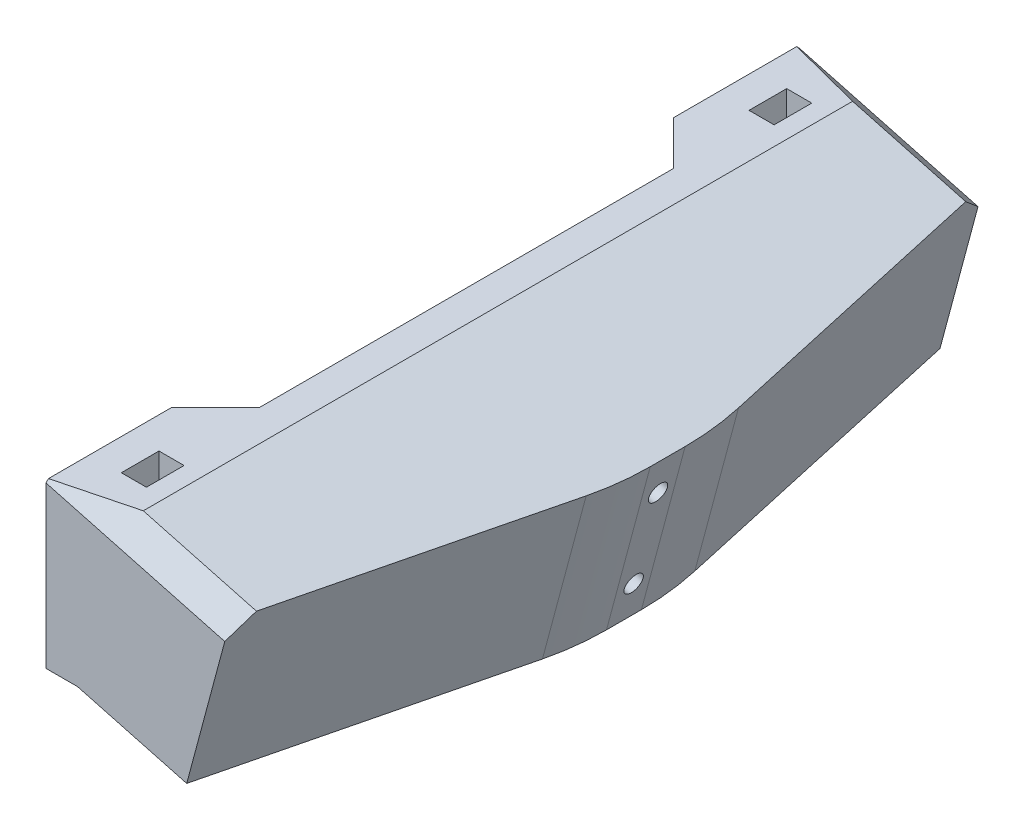
from build123d import *

# Parameters (mm, degrees)
BOSS_EXTRUDE1_DEPTH = 120
BOSS_EXTRUDE2_DEPTH = 26.917181
CUT_EXTRUDE3_DEPTH  = 34.246933562
SKETCH7_R           = 1.55
CUT_EXTRUDE4_DEPTH  = 10
CUT_EXTRUDE5_DEPTH  = 4
FILLET1_R           = 50
SKETCH10_R          = 1.5
CUT_EXTRUDE6_DEPTH  = 40.591109915
CHAMFER4_SIZE       = 3.5
SKETCH12_R          = 4
CUT_EXTRUDE8_DEPTH  = 5
SKETCH12_3_R        = 4
CUT_EXTRUDE9_DEPTH  = 9


with BuildPart() as part:
    # Sketch1 → Boss-Extrude1 (new body)
    with BuildSketch(Plane.XY):
        Polygon((12, 26), (5.033320997, 0), (22.41998587, -4.658742812), (29.386664873, 21.341257188), align=None)
        Polygon((0, 0), (0, 26), (12, 26), (5.033320997, 0), align=None)
    extrude(amount=-BOSS_EXTRUDE1_DEPTH)

    # Sketch3 → Boss-Extrude2 (add)
    with BuildSketch(Plane(origin=(7.303847577, 27.258330249, 0), x_dir=(0.965925826, -0.258819045, 0), z_dir=(0.258819045, 0.965925826, 0))):
        Polygon((22.861814743, 0), (32.861814743, 52.5), (32.861814743, 67.5), (22.861814743, 120), align=None)
    extrude(amount=-BOSS_EXTRUDE2_DEPTH)

    # Sketch6 → Cut-Extrude3 (cut, through all)
    with BuildSketch(Plane(origin=(0, 26, 0), x_dir=(1, 0, 0), z_dir=(0, 1, 0))):
        Polygon((0, 100), (7, 93), (7, 27), (0, 20), align=None)
    extrude(amount=-CUT_EXTRUDE3_DEPTH, mode=Mode.SUBTRACT)

    # Sketch7 → Cut-Extrude4 (cut)
    with BuildSketch(Plane.ZY):
        with Locations((-110, 15)):
            Circle(SKETCH7_R)
        with Locations((-10, 15)):
            Circle(SKETCH7_R)
    extrude(amount=-CUT_EXTRUDE4_DEPTH, mode=Mode.SUBTRACT)

    # Sketch8 → Cut-Extrude5 (cut)
    with BuildSketch(Plane.ZY.offset(-5)):
        Polygon((-113, 16.732050808), (-113, 26), (-107, 26), (-107, 16.732050808), (-107, 13.267949192), (-110, 11.535898385), (-113, 13.267949192), align=None)
        Polygon((-13, 26), (-13, 16.732050808), (-13, 13.267949192), (-10, 11.535898385), (-7, 13.267949192), (-7, 16.732050808), (-7, 26), align=None)
    extrude(amount=-CUT_EXTRUDE5_DEPTH, mode=Mode.SUBTRACT)

    # Fillet1
    fillet1_edges = [part.edges().sort_by_distance(p)[0] for p in [
        (35.562583594, 5.753066588, -52.5),
        (35.562583594, 5.753066588, -67.5),
    ]]
    fillet(fillet1_edges, radius=FILLET1_R)

    # Sketch10 → Cut-Extrude6 (cut, through all)
    with BuildSketch(Plane(origin=(31.742075559, -8.505263512, 0), x_dir=(0, 0, -1), z_dir=(0.965925826, -0.258819045, 0))):
        with Locations((60, 22.261309679)):
            Circle(SKETCH10_R)
        with Locations((60, 7.261309679)):
            Circle(SKETCH10_R)
    extrude(amount=-CUT_EXTRUDE6_DEPTH, mode=Mode.SUBTRACT)

    # Chamfer4
    chamfer4_edges = [part.edges().sort_by_distance(p)[0] for p in [
        (20.693332437, 23.670628594, -120),
        (20.693332437, 23.670628594, 0),
    ]]
    chamfer(chamfer4_edges, length=CHAMFER4_SIZE)

    # Sketch12 → Cut-Extrude8 (cut)
    with BuildSketch(Plane(origin=(-2.065328361, 0.553403067, 0), x_dir=(0, 0, -1), z_dir=(0.965925826, -0.258819045, 0))):
        with Locations((60, 22.261309679)):
            Circle(SKETCH12_R)
    extrude(amount=CUT_EXTRUDE8_DEPTH, mode=Mode.SUBTRACT)

    # Sketch12_3 → Cut-Extrude9 (cut)
    with BuildSketch(Plane(origin=(-2.065328361, 0.553403067, 0), x_dir=(0, 0, -1), z_dir=(0.965925826, -0.258819045, 0))):
        with Locations((60, 7.261309679)):
            Circle(SKETCH12_3_R)
    extrude(amount=CUT_EXTRUDE9_DEPTH, mode=Mode.SUBTRACT)


solid = part.part
